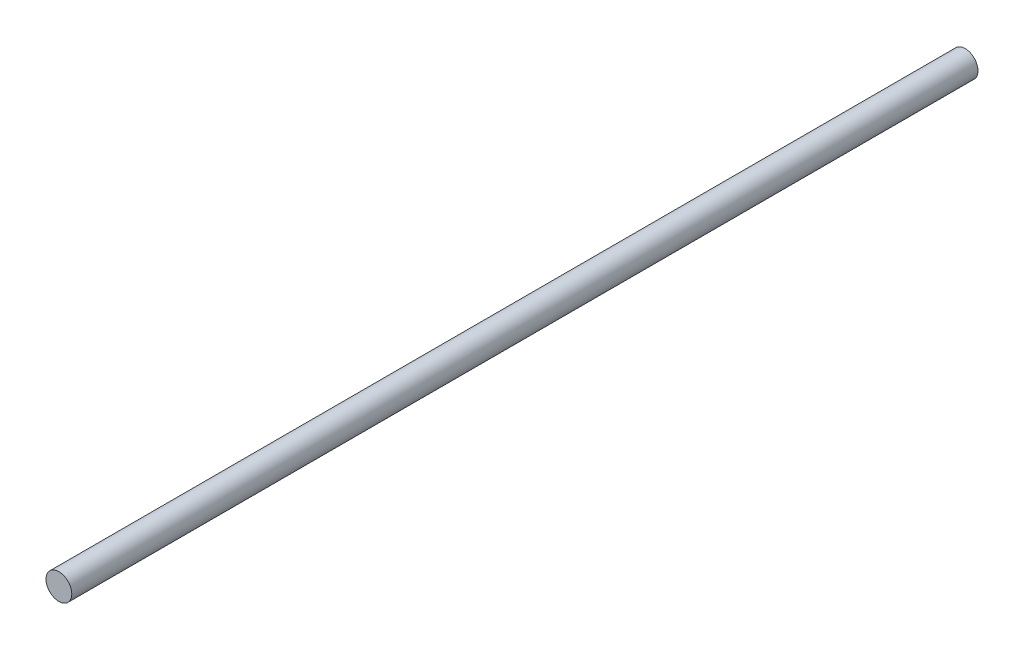
from build123d import *

# Parameters (mm, degrees)
SKETCH1_R           = 3.175
BOSS_EXTRUDE1_DEPTH = 223


with BuildPart() as part:
    # Sketch1 → Boss-Extrude1 (new body)
    with BuildSketch(Plane.XY):
        Circle(SKETCH1_R)
    extrude(amount=BOSS_EXTRUDE1_DEPTH)


solid = part.part
